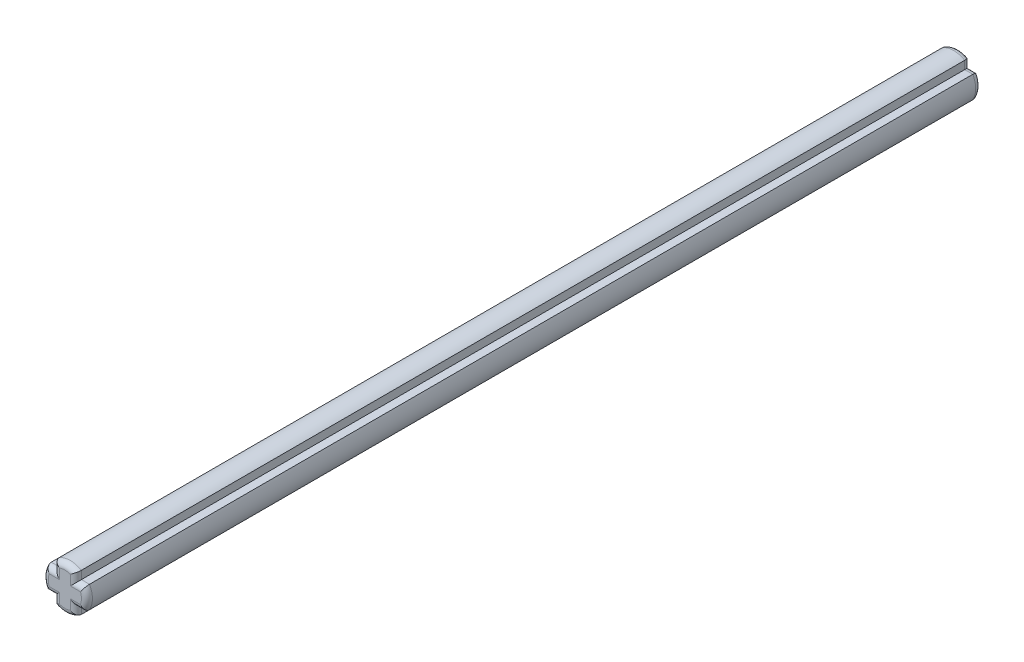
from build123d import *

# Parameters (mm, degrees)
BOSS_EXTRUDE1_DEPTH = 81
SKETCH2_OUTSIDE_W   = 22.24
SKETCH2_OUTSIDE_H   = 22.24
SKETCH2_OUTSIDE_R   = 2
CUT_EXTRUDE3_DEPTH  = 82
FILLET1_R           = 0.5


with BuildPart() as part:
    # Sketch1 → Boss-Extrude1 (new body)
    with BuildSketch(Plane.XY):
        Polygon((-1, 1), (-1, 2), (1, 2), (1, 1), (2, 1), (2, -1), (1, -1), (1, -2), (-1, -2), (-1, -1), (-2, -1), (-2, 1), align=None)
    extrude(amount=BOSS_EXTRUDE1_DEPTH)

    # Sketch2 outside → Cut-Extrude3 (cut, through all)
    with BuildSketch(Plane.XY):
        Rectangle(SKETCH2_OUTSIDE_W, SKETCH2_OUTSIDE_H)
        Circle(SKETCH2_OUTSIDE_R, mode=Mode.SUBTRACT)
    extrude(amount=CUT_EXTRUDE3_DEPTH, mode=Mode.SUBTRACT)

    # Fillet1
    fillet1_edges = [part.edges().sort_by_distance(p)[0] for p in [
        (1.366025404, -1, 0),
        (-1, -1.366025404, 0),
        (-1.366025404, 1, 0),
        (1, 1.366025404, 0),
        (-1.366025404, 1, 81),
        (-1, -1.366025404, 81),
        (1.366025404, 1, 0),
        (1, -1.366025404, 0),
        (-1.366025404, -1, 0),
        (-1, 1.366025404, 0),
        (-2, 0, 0),
        (0, 2, 0),
        (2, 0, 0),
        (0, -2, 0),
        (1.366025404, -1, 81),
        (-1, 1.366025404, 81),
        (-1.366025404, -1, 81),
        (1, -1.366025404, 81),
        (1.366025404, 1, 81),
        (1, 1.366025404, 81),
        (0, 2, 81),
        (-2, 0, 81),
        (0, -2, 81),
        (2, 0, 81),
    ]]
    fillet(fillet1_edges, radius=FILLET1_R)


solid = part.part
